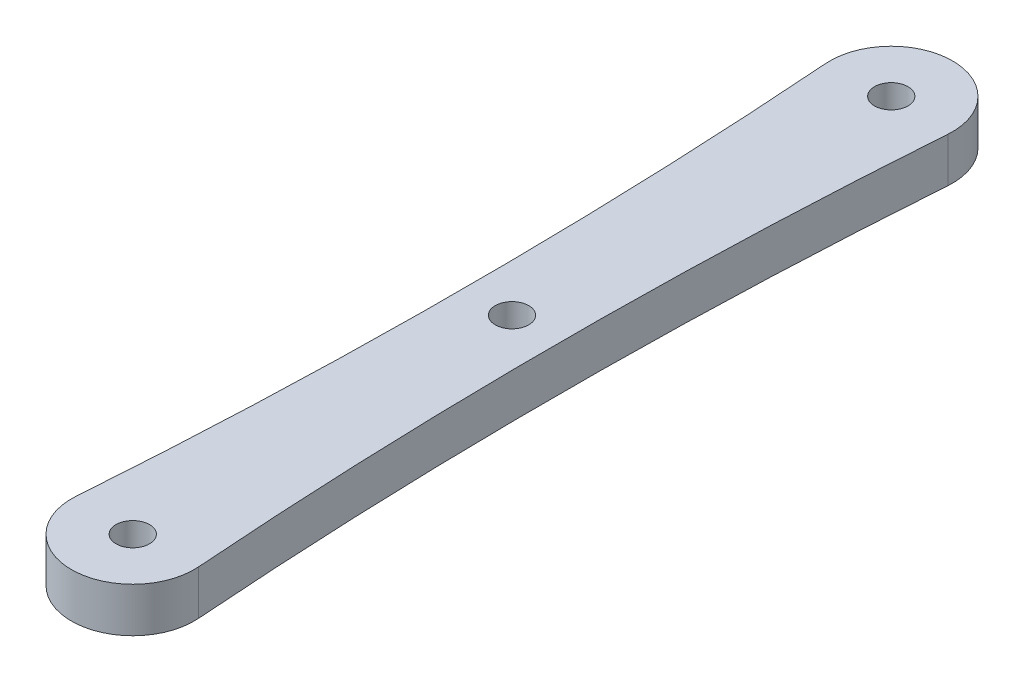
from build123d import *

# Parameters (mm, degrees)
SKETCH1_R           = 1.5
BOSS_EXTRUDE1_DEPTH = 4


with BuildPart() as part:
    # Sketch1 → Boss-Extrude1 (new body)
    with BuildSketch(Plane(origin=(0, 0, 0), x_dir=(1, 0, 0), z_dir=(0, 1, 0))):
        with BuildLine():
            ThreePointArc((-5.48515199, 0.403865882), (0, -5.5), (5.48515199, 0.403865882))
            ThreePointArc((5.48515199, 0.403865882), (4.25, 34), (5.48515199, 67.596134118))
            ThreePointArc((5.48515199, 67.596134118), (0, 73.5), (-5.48515199, 67.596134118))
            ThreePointArc((-5.48515199, 67.596134118), (-4.25, 34), (-5.48515199, 0.403865882))
        make_face()
        Circle(SKETCH1_R, mode=Mode.SUBTRACT)
        with Locations((0, 68)):
            Circle(SKETCH1_R, mode=Mode.SUBTRACT)
        with Locations((0, 34)):
            Circle(SKETCH1_R, mode=Mode.SUBTRACT)
    extrude(amount=BOSS_EXTRUDE1_DEPTH)


solid = part.part
